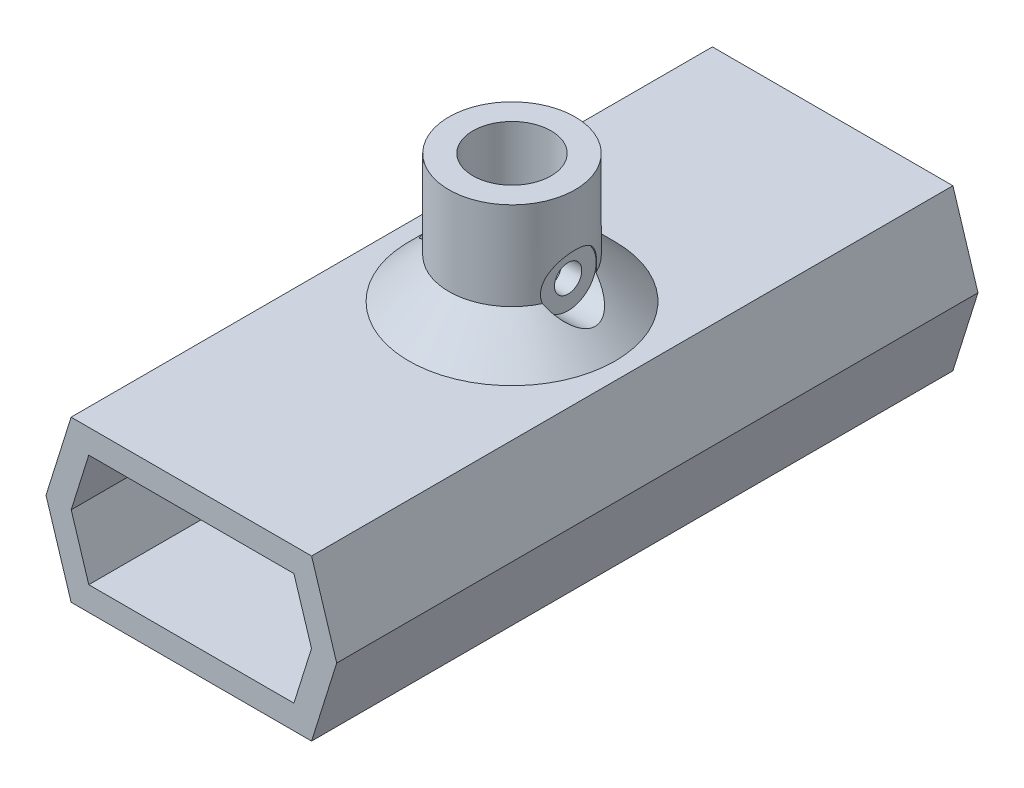
from build123d import *

# Parameters (mm, degrees)
EXTRUDE_1_DEPTH          = 40
CUT_EXTRUDE_3_DEPTH      = 85.431707145
CHAMFER_1_SIZE           = 5
CUT_EXTRUDE_1_DEPTH      = 10
CUT_EXTRUDE_1_DEPTH_BACK = 10
SKETCH_5_R               = 1.7
SKETCH_6_R               = 3.5
CUT_EXTRUDE_2_DEPTH      = 10
CUT_EXTRUDE_4_DEPTH      = 0.6
CUT_EXTRUDE_5_DEPTH      = 0.6
SKETCH_10_R              = 0.90757886
CUT_EXTRUDE_6_DEPTH      = 1


with BuildPart() as part:
    # 草图1 → 凸台-拉伸1 (new, symmetric)
    with BuildSketch(Plane.XY):
        Polygon((-15, 0), (15, 0), (18.130448736, -10), (15, -20), (-15, -20), (-18.130448736, -10), align=None)
    extrude(amount=EXTRUDE_1_DEPTH, both=True)

    # 草图7 → 切除-拉伸3 (cut, through all)
    with BuildSketch(Plane(origin=(0, 0, -40), x_dir=(-1, 0, 0), z_dir=(0, 0, -1))):
        Polygon((14.986888042, -10), (12.795573927, -3), (-12.795573927, -3), (-14.986888042, -10), (-12.795573927, -17), (12.795573927, -17), align=None)
    extrude(amount=-CUT_EXTRUDE_3_DEPTH, mode=Mode.SUBTRACT)

    # 草图3 → 旋转1 (revolve)
    with BuildSketch(Plane.XY):
        Polygon((4.875, 16), (7.875, 16), (7.875, 0), (0, 0), (0, 2), (4.875, 2), align=None)
    revolve(axis=Axis((0, 0, 0), (0, 1, 0)))

    # 倒角1
    chamfer_1_edges = [part.edges().sort_by_distance(p)[0] for p in [
        (-7.875, 0, 0),
    ]]
    chamfer(chamfer_1_edges, length=CHAMFER_1_SIZE)

    # 草图5 → 切除-拉伸1 (cut, two sides: drawn at the far end of the back side and taken through both)
    with BuildSketch(Plane(origin=(0, 0, 0), x_dir=(0, 0, -1), z_dir=(1, 0, 0)).offset(-CUT_EXTRUDE_1_DEPTH_BACK)):
        with Locations((0, 6)):
            Circle(SKETCH_5_R)
    extrude(amount=CUT_EXTRUDE_1_DEPTH + CUT_EXTRUDE_1_DEPTH_BACK, mode=Mode.SUBTRACT)

    # 草图6 → 切除-拉伸2 (cut)
    with BuildSketch(Plane(origin=(7, 0, 0), x_dir=(0, 0, -1), z_dir=(1, 0, 0))):
        with Locations((0, 6)):
            Circle(SKETCH_6_R)
    cut_extrude_2 = extrude(amount=CUT_EXTRUDE_2_DEPTH, mode=Mode.SUBTRACT)

    # 镜向1: 切除-拉伸2 across plane
    add(cut_extrude_2.mirror(Plane(origin=(0, 0, 0), x_dir=(0, 0, 1), z_dir=(1, 0, 0))), mode=Mode.SUBTRACT)

    # 草图8 → 切除-拉伸4 (cut)
    with BuildSketch(Plane.XZ.offset(20)):
        Polygon((-0.3, 0), (-0.3, -9.488320233), (-0.9, -9.488320233), (0, -10.399776511), (0.9, -9.488320233), (0.3, -9.488320233), (0.3, 0), align=None)
        Polygon((0, -0.3), (9.488320233, -0.3), (9.488320233, -0.9), (10.399776511, 0), (9.488320233, 0.9), (9.488320233, 0.3), (0, 0.3), align=None)
    extrude(amount=-CUT_EXTRUDE_4_DEPTH, mode=Mode.SUBTRACT)

    # 草图9 → 切除-拉伸5 (cut)
    with BuildSketch(Plane.XZ.offset(20)):
        Polygon((1.036018744, -10.883097159), (1.036018744, -11.163798913), (0.217305293, -11.561459732), (1.036018744, -11.959120551), (1.036018744, -12.239822305), (-0.016612835, -11.690114703), (-0.963981256, -12.181342773), (-0.963981256, -11.900641018), (-0.238835058, -11.561459732), (-0.963981256, -11.222278445), (-0.963981256, -10.941576691), (-0.016612835, -11.432804761), align=None)
        Polygon((10.812249856, -2.737510211), (9.712834652, -2.187802609), (8.812249856, -2.187802609), (8.812249856, -1.918796761), (9.712834652, -1.918796761), (10.812249856, -1.369089158), (10.812249856, -1.638095006), (9.958448687, -2.047451731), (9.958448687, -2.059147638), (10.812249856, -2.468504363), align=None)
    extrude(amount=-CUT_EXTRUDE_5_DEPTH, mode=Mode.SUBTRACT)

    # 草图10 → 切除-拉伸6 (cut)
    with BuildSketch(Plane(origin=(0, 2, 0), x_dir=(1, 0, 0), z_dir=(0, 1, 0))):
        Circle(SKETCH_10_R)
    extrude(amount=-CUT_EXTRUDE_6_DEPTH, mode=Mode.SUBTRACT)


solid = part.part
